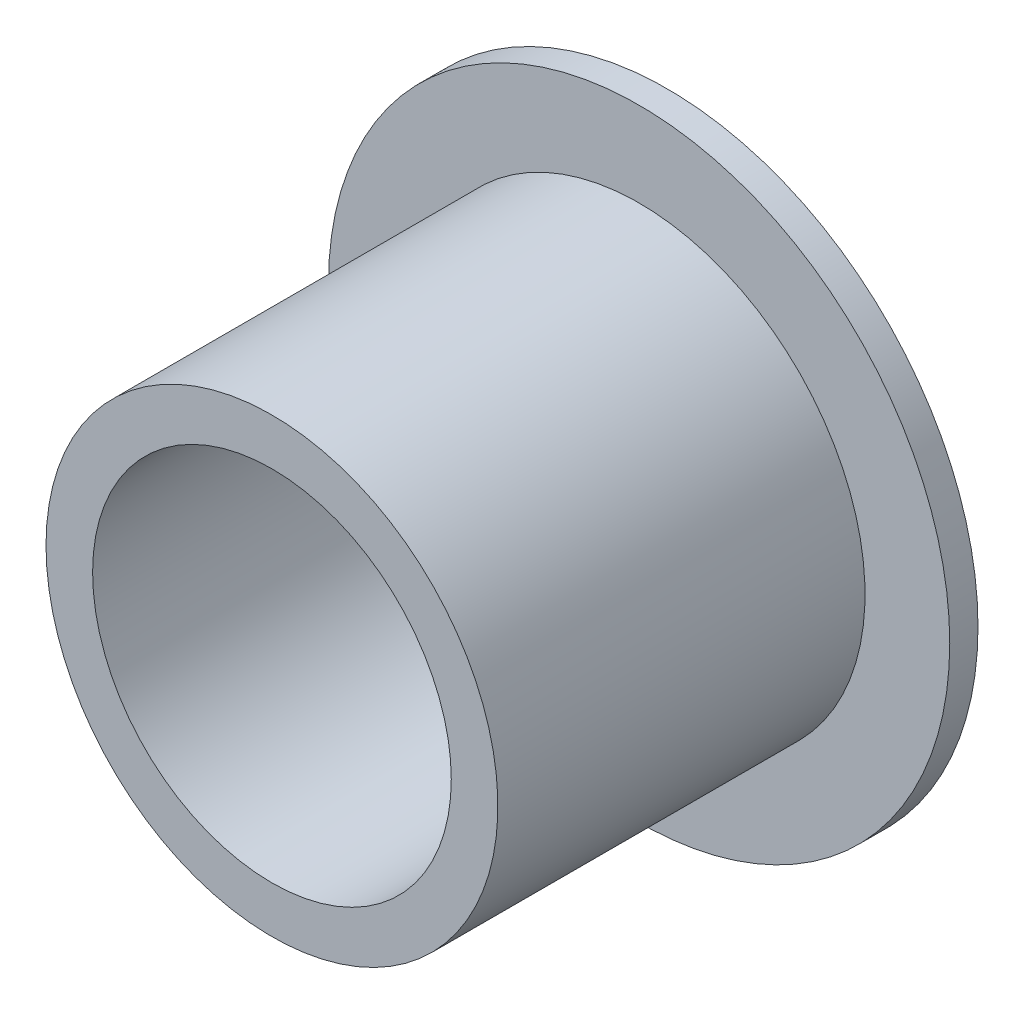
from build123d import *


with BuildPart() as part:
    # Sketch1 → Revolve1 (revolve)
    with BuildSketch(Plane(origin=(0, 0, 0), x_dir=(0, 0, -1), z_dir=(1, 0, 0))):
        Polygon((0, 6.35), (0, 11), (-1, 11), (-1, 8), (-14, 8), (-14, 6.35), align=None)
    revolve(axis=Axis((0, 0, 0), (0, 0, 1)))


solid = part.part
